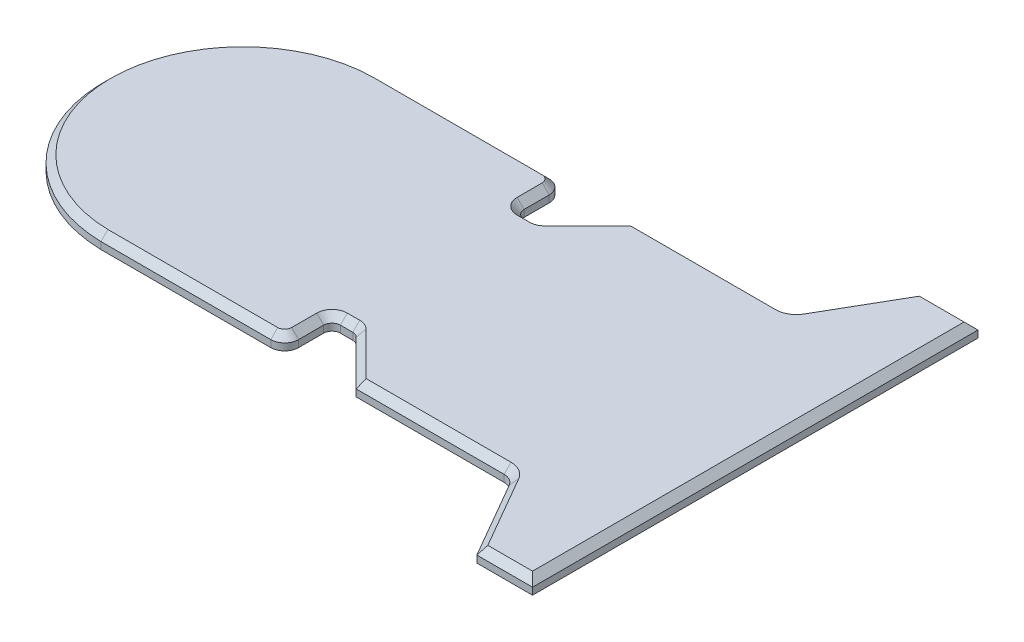
from build123d import *

# Parameters (mm, degrees)
BOSS_EXTRUDE1_DEPTH = 5
CHAMFER1_SIZE       = 2.5


with BuildPart() as part:
    # Sketch1 → Boss-Extrude1 (new body)
    with BuildSketch(Plane(origin=(0, 0, 0), x_dir=(1, 0, 0), z_dir=(0, 1, 0))):
        with BuildLine():
            Line((15.254575611, 35.990242765), (15.254575611, 44.990242765))
            ThreePointArc((15.254575611, 44.990242765), (13.790109517, 48.525776671), (10.254575611, 49.990242765))
            Line((10.254575611, 49.990242765), (-50.745424389, 49.990242765))
            ThreePointArc((-50.745424389, 49.990242765), (-99.757685432, 0), (-50.745424389, -49.990242765))
            Line((-50.745424389, -49.990242765), (10.254575611, -49.990242765))
            ThreePointArc((10.254575611, -49.990242765), (13.790109517, -48.525776671), (15.254575611, -44.990242765))
            Line((15.254575611, -44.990242765), (15.254575611, -35.990242765))
            ThreePointArc((15.254575611, -35.990242765), (16.133255268, -33.868922422), (18.254575611, -32.990242765))
            Line((18.254575611, -32.990242765), (22.711934924, -32.990242765))
            ThreePointArc((22.711934924, -32.990242765), (23.859985221, -33.218604168), (24.833255268, -33.868922422))
            Line((24.833255268, -33.868922422), (40.954575611, -49.990242765))
            Line((40.954575611, -49.990242765), (50.745424389, -49.990242765))
            Line((50.745424389, -49.990242765), (94.067824265, -49.990242765))
            ThreePointArc((94.067824265, -49.990242765), (96.567824265, -50.660115747), (98.397951284, -52.490242765))
            Line((98.397951284, -52.490242765), (114.280717029, -80))
            Line((114.280717029, -80), (134.280717029, -80))
            Line((134.280717029, -80), (134.280717029, 80))
            Line((134.280717029, 80), (114.280717029, 80))
            Line((114.280717029, 80), (98.397951284, 52.490242765))
            ThreePointArc((98.397951284, 52.490242765), (96.567824265, 50.660115747), (94.067824265, 49.990242765))
            Line((94.067824265, 49.990242765), (50.745424389, 49.990242765))
            Line((50.745424389, 49.990242765), (40.954575611, 49.990242765))
            Line((40.954575611, 49.990242765), (24.833255268, 33.868922422))
            ThreePointArc((24.833255268, 33.868922422), (23.859985221, 33.218604168), (22.711934924, 32.990242765))
            Line((22.711934924, 32.990242765), (18.254575611, 32.990242765))
            ThreePointArc((18.254575611, 32.990242765), (16.133255268, 33.868922422), (15.254575611, 35.990242765))
        make_face()
    extrude(amount=BOSS_EXTRUDE1_DEPTH)

    # Chamfer1
    chamfer1_edges = [part.edges().sort_by_distance(p)[0] for p in [
        (96.567824265, 5, 50.660115747),
        (106.339334157, 5, 66.245121383),
        (96.567824265, 5, -50.660115747),
        (124.280717029, 5, 80),
        (134.280717029, 5, 0),
        (124.280717029, 5, -80),
        (67.511199938, 5, -49.990242765),
        (32.893915439, 5, -41.929582594),
        (23.859985221, 5, -33.218604168),
        (20.483255268, 5, -32.990242765),
        (16.133255268, 5, -33.868922422),
        (15.254575611, 5, -40.490242765),
        (13.790109517, 5, -48.525776671),
        (-20.245424389, 5, -49.990242765),
        (-99.757685432, 5, 0),
        (106.339334157, 5, -66.245121383),
        (-20.245424389, 5, 49.990242765),
        (13.790109517, 5, 48.525776671),
        (15.254575611, 5, 40.490242765),
        (16.133255268, 5, 33.868922422),
        (20.483255268, 5, 32.990242765),
        (23.859985221, 5, 33.218604168),
        (32.893915439, 5, 41.929582594),
        (67.511199938, 5, 49.990242765),
    ]]
    chamfer(chamfer1_edges, length=CHAMFER1_SIZE)


solid = part.part
